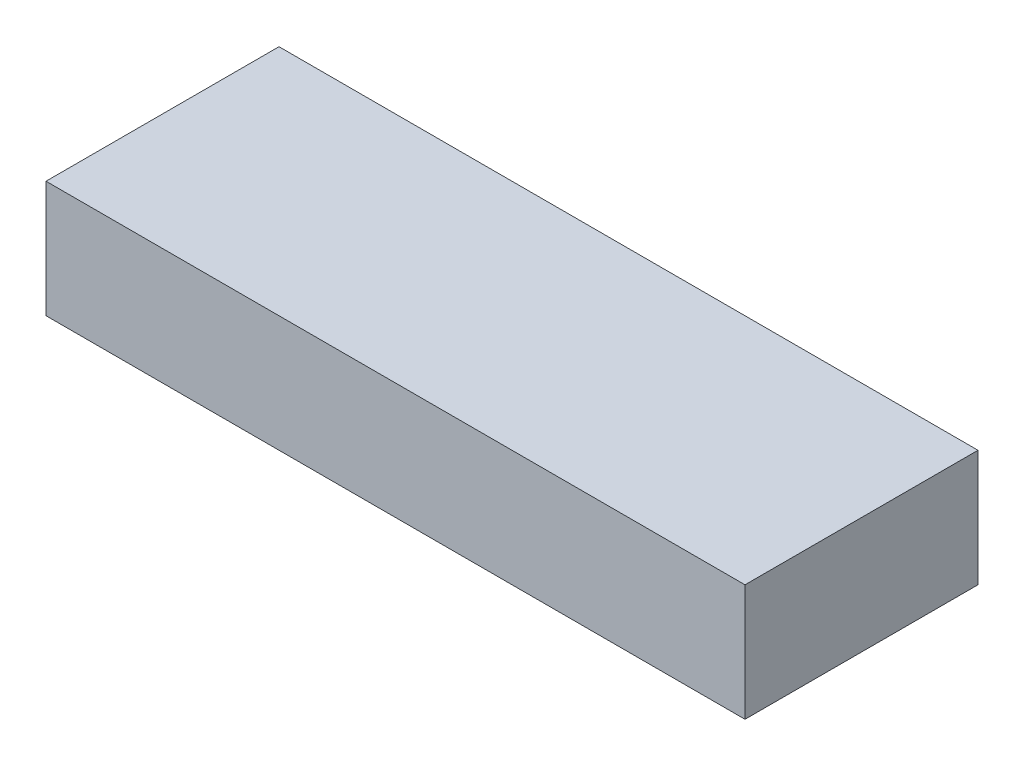
from build123d import *

# Parameters (mm, degrees)
SKETCH1_W             = 38.1
SKETCH1_H             = 12.7
BOSS_EXTRUDE1_DEPTH   = 6.35
BOSS_EXTRUDE2_DEPTH   = 0.508
BOSS_EXTRUDE2_2_DEPTH = 0.508
BOSS_EXTRUDE2_3_DEPTH = 0.508
BOSS_EXTRUDE2_4_DEPTH = 0.508
BOSS_EXTRUDE2_5_DEPTH = 0.508
BOSS_EXTRUDE2_6_DEPTH = 0.508


with BuildPart() as part:
    # Sketch1 → Boss-Extrude1 (new body)
    with BuildSketch(Plane(origin=(0, 0, 0), x_dir=(1, 0, 0), z_dir=(0, 1, 0))):
        Rectangle(SKETCH1_W, SKETCH1_H)
    extrude(amount=BOSS_EXTRUDE1_DEPTH)


with BuildPart() as body_2:
    # Sketch2 → Boss-Extrude2 (new body)
    with BuildSketch(Plane(origin=(0, 6.35, 0), x_dir=(1, 0, 0), z_dir=(0, 1, 0))):
        Polygon((-12.522431526, 2.146065762), (-11.733769667, 2.146065762), (-10.767870896, -0.80675208), (-9.795187936, 2.146065762), (-9.014158289, 2.146065762), (-8.298426451, -2.087267571), (-9.06758377, -2.087267571), (-9.519580298, 0.586550538), (-10.399828695, -2.087267571), (-11.141001238, -2.087267571), (-12.016161494, 0.586550538), (-12.467309998, -2.087267571), (-13.23731534, -2.087267571), align=None)
    extrude(amount=-BOSS_EXTRUDE2_DEPTH)


with BuildPart() as body_3:
    # Sketch2 → Boss-Extrude2 2 (new body)
    with BuildSketch(Plane(origin=(0, 6.35, 0), x_dir=(1, 0, 0), z_dir=(0, 1, 0))):
        with BuildLine():
            add(Edge.make_bspline(
                [(-5.603407755, 2.254612771), (-5.529806067, 2.252707091), (-5.384499664, 2.248944848), (-5.17080638, 2.217583617), (-4.96487339, 2.166484986), (-4.766793816, 2.095454193), (-4.577063625, 2.002567364), (-4.395013576, 1.8904579), (-4.221295764, 1.757009803), (-4.057690309, 1.605336197), (-3.906489362, 1.440397773), (-3.775473653, 1.262812236), (-3.663748263, 1.077181005), (-3.571149961, 0.883006677), (-3.500619118, 0.678944501), (-3.451124709, 0.466034924), (-3.419327003, 0.244338519), (-3.415669777, 0.093393484), (-3.413811067, 0.016678743)],
                knots=[0, 0, 0, 0, 0.000220721, 0.000435753, 0.000646365, 0.000856403, 0.00106576, 0.001278984, 0.001496765, 0.001721811, 0.001947536, 0.002167008, 0.002382688, 0.002596632, 0.002811184, 0.003029014, 0.003251603, 0.003481643, 0.003481643, 0.003481643, 0.003481643], degree=3))
            add(Edge.make_bspline(
                [(-3.413811067, 0.016678743), (-3.415790513, -0.0591716), (-3.419691075, -0.208637134), (-3.449826587, -0.42829052), (-3.500154489, -0.638919392), (-3.569489073, -0.841000511), (-3.660407992, -1.033555067), (-3.769954615, -1.217812494), (-3.90101967, -1.392062839), (-4.048822699, -1.556212592), (-4.211541007, -1.705213715), (-4.383885526, -1.836520698), (-4.565060476, -1.94778528), (-4.754800675, -2.038956497), (-4.95351301, -2.10971112), (-5.16070664, -2.159633649), (-5.376368742, -2.189972577), (-5.52302943, -2.193847661), (-5.59747159, -2.19581458)],
                knots=[0, 0, 0, 0, 0.000227498, 0.000448292, 0.000663647, 0.000876318, 0.001088005, 0.001301358, 0.001518283, 0.001741042, 0.001963118, 0.002179197, 0.002390088, 0.002599839, 0.002809591, 0.003021648, 0.003238241, 0.003461503, 0.003461503, 0.003461503, 0.003461503], degree=3))
            add(Edge.make_bspline(
                [(-5.59747159, -2.19581458), (-5.675329164, -2.194050157), (-5.828308655, -2.190583307), (-6.052194825, -2.157615148), (-6.266697121, -2.107953584), (-6.470013601, -2.033836364), (-6.664214868, -1.941183606), (-6.84787407, -1.82707618), (-7.020929484, -1.691702657), (-7.182388437, -1.538530004), (-7.32867064, -1.370925525), (-7.457793377, -1.193866256), (-7.56671127, -1.008704774), (-7.655428304, -0.81535442), (-7.72536925, -0.615016819), (-7.774704641, -0.406471856), (-7.803848233, -0.1902197), (-7.807907766, -0.043336912), (-7.809964913, 0.031095143)],
                knots=[0, 0, 0, 0, 0.000233428, 0.000458655, 0.000677506, 0.000892905, 0.001106449, 0.001322007, 0.001540154, 0.0017645, 0.001988669, 0.002206638, 0.002421018, 0.00263199, 0.002843861, 0.003056544, 0.003273863, 0.003497125, 0.003497125, 0.003497125, 0.003497125], degree=3))
            add(Edge.make_bspline(
                [(-7.809964913, 0.031095143), (-7.809319262, 0.081169133), (-7.808036135, 0.180683061), (-7.792579523, 0.328157623), (-7.770326445, 0.47275368), (-7.737415198, 0.613894725), (-7.697436445, 0.752576442), (-7.645638323, 0.887507948), (-7.586678043, 1.020130682), (-7.517788507, 1.148878203), (-7.441190004, 1.272565928), (-7.357614217, 1.390610398), (-7.266850996, 1.501584285), (-7.16919272, 1.606216862), (-7.064302845, 1.703820373), (-6.953561089, 1.79577653), (-6.834819707, 1.879642652), (-6.710677575, 1.957466916), (-6.581834577, 2.027842048), (-6.448815223, 2.087743256), (-6.314359972, 2.140053961), (-6.176672685, 2.181339882), (-6.037228925, 2.214966832), (-5.894539019, 2.237204912), (-5.749892088, 2.252661096), (-5.652351745, 2.253960669), (-5.603407755, 2.254612771)],
                knots=[0, 0, 0, 0, 0.00015016, 0.000298419, 0.00044439, 0.000588803, 0.000732899, 0.000877016, 0.001022016, 0.001168075, 0.001314688, 0.001458222, 0.001601661, 0.001744456, 0.001887252, 0.002031229, 0.002175945, 0.002323006, 0.002470616, 0.002615965, 0.002760383, 0.002903098, 0.003046877, 0.003190336, 0.003336063, 0.003482832, 0.003482832, 0.003482832, 0.003482832], degree=3))
        make_face()
        with BuildLine():
            add(Edge.make_bspline(
                [(-5.615280084, 1.494783711), (-5.66481401, 1.493454604), (-5.762574159, 1.49083148), (-5.905970494, 1.470846821), (-6.04363604, 1.438929048), (-6.174807662, 1.392696545), (-6.300053869, 1.333854302), (-6.419596684, 1.262607922), (-6.531780686, 1.176508389), (-6.638101741, 1.080178004), (-6.734145319, 0.972843817), (-6.819002849, 0.857816981), (-6.890014935, 0.73528959), (-6.949488001, 0.606399894), (-6.994258039, 0.469698562), (-7.026146395, 0.326256391), (-7.046298645, 0.175826223), (-7.048838861, 0.073278173), (-7.050135853, 0.02091886)],
                knots=[0, 0, 0, 0, 0.000148559, 0.000293196, 0.000433479, 0.000571871, 0.00070958, 0.000848034, 0.000988469, 0.001133133, 0.001277857, 0.001419824, 0.001561198, 0.001701985, 0.001844919, 0.001991813, 0.002142335, 0.002299366, 0.002299366, 0.002299366, 0.002299366], degree=3))
            add(Edge.make_bspline(
                [(-7.050135853, 0.02091886), (-7.04841624, -0.037107036), (-7.045046083, -0.150828179), (-7.021333251, -0.316721518), (-6.980762956, -0.473391311), (-6.922180239, -0.620071311), (-6.8495223, -0.758390289), (-6.759292671, -0.886652949), (-6.652952646, -1.005627268), (-6.571029151, -1.075089431), (-6.529449421, -1.110344494)],
                knots=[0, 0, 0, 0, 0.000174052, 0.000341112, 0.00050155, 0.000658395, 0.000813933, 0.000969205, 0.001127733, 0.001291118, 0.001291118, 0.001291118, 0.001291118], degree=3))
            add(Edge.make_bspline(
                [(-6.529449421, -1.110344494), (-6.495387685, -1.136389581), (-6.428031628, -1.187892954), (-6.320516696, -1.253905093), (-6.209797487, -1.310484081), (-6.095038486, -1.356199233), (-5.976482057, -1.392158004), (-5.854144458, -1.41733934), (-5.728199032, -1.433142806), (-5.643028832, -1.43503162), (-5.600015661, -1.43598552)],
                knots=[0, 0, 0, 0, 0.000128564, 0.000254232, 0.000377869, 0.000501171, 0.00062431, 0.000749047, 0.00087548, 0.00100448, 0.00100448, 0.00100448, 0.00100448], degree=3))
            add(Edge.make_bspline(
                [(-5.600015661, -1.43598552), (-5.551333471, -1.434645144), (-5.455549733, -1.432007912), (-5.314822798, -1.412269275), (-5.18000212, -1.378864375), (-5.050250721, -1.333037439), (-4.925942746, -1.273456381), (-4.807685722, -1.200000161), (-4.695272312, -1.113570728), (-4.589086709, -1.015975314), (-4.492028048, -0.908218304), (-4.407347598, -0.792577927), (-4.334077683, -0.671602087), (-4.27584136, -0.543578553), (-4.229302559, -0.409715809), (-4.197797996, -0.269421004), (-4.177475505, -0.123272487), (-4.174934573, -0.023813257), (-4.173640127, 0.026855025)],
                knots=[0, 0, 0, 0, 0.000146018, 0.000287294, 0.000425304, 0.000562096, 0.000699402, 0.000838015, 0.000978963, 0.0011242, 0.001270122, 0.001413275, 0.001553619, 0.001693636, 0.001834431, 0.001978017, 0.002124335, 0.002276283, 0.002276283, 0.002276283, 0.002276283], degree=3))
            add(Edge.make_bspline(
                [(-4.173640127, 0.026855025), (-4.174979361, 0.07723195), (-4.17761544, 0.176391245), (-4.197388818, 0.322164015), (-4.230581874, 0.461839459), (-4.276546423, 0.595645683), (-4.335240718, 0.723713866), (-4.407822168, 0.845593644), (-4.494036094, 0.961167191), (-4.591898288, 1.069646915), (-4.698415271, 1.169332833), (-4.812771895, 1.255842089), (-4.931768334, 1.331015882), (-5.058134947, 1.389903996), (-5.189286378, 1.436820031), (-5.32602292, 1.471369673), (-5.468862472, 1.490691087), (-5.566039172, 1.493407343), (-5.615280084, 1.494783711)],
                knots=[0, 0, 0, 0, 0.000151101, 0.000297418, 0.000440373, 0.000581168, 0.000721184, 0.000862257, 0.001005914, 0.001153033, 0.001300045, 0.001442855, 0.001582635, 0.001721473, 0.001860148, 0.002000007, 0.002143804, 0.002291516, 0.002291516, 0.002291516, 0.002291516], degree=3))
        make_face(mode=Mode.SUBTRACT)
    extrude(amount=-BOSS_EXTRUDE2_2_DEPTH)


with BuildPart() as body_4:
    # Sketch2 → Boss-Extrude2 3 (new body)
    with BuildSketch(Plane(origin=(0, 6.35, 0), x_dir=(1, 0, 0), z_dir=(0, 1, 0))):
        Polygon((-3.088170041, 2.146065762), (-0.808682862, 2.146065762), (-0.808682862, 1.386236702), (-1.568511921, 1.386236702), (-1.568511921, -2.087267571), (-2.328340981, -2.087267571), (-2.328340981, 1.386236702), (-3.088170041, 1.386236702), align=None)
    extrude(amount=-BOSS_EXTRUDE2_3_DEPTH)


with BuildPart() as body_5:
    # Sketch2 → Boss-Extrude2 4 (new body)
    with BuildSketch(Plane(origin=(0, 6.35, 0), x_dir=(1, 0, 0), z_dir=(0, 1, 0))):
        with BuildLine():
            add(Edge.make_bspline(
                [(1.777788826, 2.254612771), (1.851390515, 2.252707091), (1.996696918, 2.248944848), (2.210390201, 2.217583617), (2.416323191, 2.166484986), (2.614402766, 2.095454193), (2.804132956, 2.002567364), (2.986183005, 1.8904579), (3.159900817, 1.757009803), (3.323506272, 1.605336197), (3.474707219, 1.440397773), (3.605722928, 1.262812236), (3.717448318, 1.077181005), (3.810046621, 0.883006677), (3.880577463, 0.678944501), (3.930071873, 0.466034924), (3.961869579, 0.244338519), (3.965526804, 0.093393484), (3.967385514, 0.016678743)],
                knots=[0, 0, 0, 0, 0.000220721, 0.000435753, 0.000646365, 0.000856403, 0.00106576, 0.001278984, 0.001496765, 0.001721811, 0.001947536, 0.002167008, 0.002382688, 0.002596632, 0.002811184, 0.003029014, 0.003251603, 0.003481643, 0.003481643, 0.003481643, 0.003481643], degree=3))
            add(Edge.make_bspline(
                [(3.967385514, 0.016678743), (3.965406068, -0.0591716), (3.961505506, -0.208637134), (3.931369994, -0.42829052), (3.881042093, -0.638919392), (3.811707508, -0.841000511), (3.720788589, -1.033555067), (3.611241966, -1.217812494), (3.480176911, -1.392062839), (3.332373882, -1.556212592), (3.169655575, -1.705213715), (2.997311055, -1.836520698), (2.816136105, -1.94778528), (2.626395907, -2.038956497), (2.427683571, -2.10971112), (2.220489941, -2.159633649), (2.004827839, -2.189972577), (1.858167152, -2.193847661), (1.783724991, -2.19581458)],
                knots=[0, 0, 0, 0, 0.000227498, 0.000448292, 0.000663647, 0.000876318, 0.001088005, 0.001301358, 0.001518283, 0.001741042, 0.001963118, 0.002179197, 0.002390088, 0.002599839, 0.002809591, 0.003021648, 0.003238241, 0.003461503, 0.003461503, 0.003461503, 0.003461503], degree=3))
            add(Edge.make_bspline(
                [(1.783724991, -2.19581458), (1.705867417, -2.194050157), (1.552887926, -2.190583307), (1.329001756, -2.157615148), (1.11449946, -2.107953584), (0.911182981, -2.033836364), (0.716981713, -1.941183606), (0.533322511, -1.82707618), (0.360267097, -1.691702657), (0.198808144, -1.538530004), (0.052525941, -1.370925525), (-0.076596796, -1.193866256), (-0.185514689, -1.008704774), (-0.274231723, -0.81535442), (-0.344172669, -0.615016819), (-0.39350806, -0.406471856), (-0.422651652, -0.1902197), (-0.426711185, -0.043336912), (-0.428768332, 0.031095143)],
                knots=[0, 0, 0, 0, 0.000233428, 0.000458655, 0.000677506, 0.000892905, 0.001106449, 0.001322007, 0.001540154, 0.0017645, 0.001988669, 0.002206638, 0.002421018, 0.00263199, 0.002843861, 0.003056544, 0.003273863, 0.003497125, 0.003497125, 0.003497125, 0.003497125], degree=3))
            add(Edge.make_bspline(
                [(-0.428768332, 0.031095143), (-0.428122681, 0.081169133), (-0.426839554, 0.180683061), (-0.411382941, 0.328157623), (-0.389129863, 0.47275368), (-0.356218617, 0.613894725), (-0.316239864, 0.752576442), (-0.264441742, 0.887507948), (-0.205481462, 1.020130682), (-0.136591926, 1.148878203), (-0.059993422, 1.272565928), (0.023582364, 1.390610398), (0.114345585, 1.501584285), (0.212003861, 1.606216862), (0.316893736, 1.703820373), (0.427635492, 1.79577653), (0.546376874, 1.879642652), (0.670519006, 1.957466916), (0.799362004, 2.027842048), (0.932381359, 2.087743256), (1.066836609, 2.140053961), (1.204523896, 2.181339882), (1.343967656, 2.214966832), (1.486657562, 2.237204912), (1.631304493, 2.252661096), (1.728844836, 2.253960669), (1.777788826, 2.254612771)],
                knots=[0, 0, 0, 0, 0.00015016, 0.000298419, 0.00044439, 0.000588803, 0.000732899, 0.000877016, 0.001022016, 0.001168075, 0.001314688, 0.001458222, 0.001601661, 0.001744456, 0.001887252, 0.002031229, 0.002175945, 0.002323006, 0.002470616, 0.002615965, 0.002760383, 0.002903098, 0.003046877, 0.003190336, 0.003336063, 0.003482832, 0.003482832, 0.003482832, 0.003482832], degree=3))
        make_face()
        with BuildLine():
            add(Edge.make_bspline(
                [(1.765916497, 1.494783711), (1.716382571, 1.493454604), (1.618622422, 1.49083148), (1.475226087, 1.470846821), (1.337560541, 1.438929048), (1.206388919, 1.392696545), (1.081142712, 1.333854302), (0.961599897, 1.262607922), (0.849415895, 1.176508389), (0.74309484, 1.080178004), (0.647051262, 0.972843817), (0.562193732, 0.857816981), (0.491181646, 0.73528959), (0.43170858, 0.606399894), (0.386938542, 0.469698562), (0.355050187, 0.326256391), (0.334897936, 0.175826223), (0.33235772, 0.073278173), (0.331060728, 0.02091886)],
                knots=[0, 0, 0, 0, 0.000148559, 0.000293196, 0.000433479, 0.000571871, 0.00070958, 0.000848034, 0.000988469, 0.001133133, 0.001277857, 0.001419824, 0.001561198, 0.001701985, 0.001844919, 0.001991813, 0.002142335, 0.002299366, 0.002299366, 0.002299366, 0.002299366], degree=3))
            add(Edge.make_bspline(
                [(0.331060728, 0.02091886), (0.332780341, -0.037107036), (0.336150498, -0.150828179), (0.35986333, -0.316721518), (0.400433625, -0.473391311), (0.459016342, -0.620071311), (0.531674281, -0.758390289), (0.62190391, -0.886652949), (0.728243936, -1.005627268), (0.81016743, -1.075089431), (0.85174716, -1.110344494)],
                knots=[0, 0, 0, 0, 0.000174052, 0.000341112, 0.00050155, 0.000658395, 0.000813933, 0.000969205, 0.001127733, 0.001291118, 0.001291118, 0.001291118, 0.001291118], degree=3))
            add(Edge.make_bspline(
                [(0.85174716, -1.110344494), (0.885808897, -1.136389581), (0.953164954, -1.187892954), (1.060679885, -1.253905093), (1.171399094, -1.310484081), (1.286158096, -1.356199233), (1.404714524, -1.392158004), (1.527052123, -1.41733934), (1.652997549, -1.433142806), (1.738167749, -1.43503162), (1.78118092, -1.43598552)],
                knots=[0, 0, 0, 0, 0.000128564, 0.000254232, 0.000377869, 0.000501171, 0.00062431, 0.000749047, 0.00087548, 0.00100448, 0.00100448, 0.00100448, 0.00100448], degree=3))
            add(Edge.make_bspline(
                [(1.78118092, -1.43598552), (1.82986311, -1.434645144), (1.925646848, -1.432007912), (2.066373783, -1.412269275), (2.201194461, -1.378864375), (2.33094586, -1.333037439), (2.455253835, -1.273456381), (2.573510859, -1.200000161), (2.685924269, -1.113570728), (2.792109872, -1.015975314), (2.889168533, -0.908218304), (2.973848983, -0.792577927), (3.047118898, -0.671602087), (3.105355221, -0.543578553), (3.151894022, -0.409715809), (3.183398585, -0.269421004), (3.203721076, -0.123272487), (3.206262008, -0.023813257), (3.207556455, 0.026855025)],
                knots=[0, 0, 0, 0, 0.000146018, 0.000287294, 0.000425304, 0.000562096, 0.000699402, 0.000838015, 0.000978963, 0.0011242, 0.001270122, 0.001413275, 0.001553619, 0.001693636, 0.001834431, 0.001978017, 0.002124335, 0.002276283, 0.002276283, 0.002276283, 0.002276283], degree=3))
            add(Edge.make_bspline(
                [(3.207556455, 0.026855025), (3.20621722, 0.07723195), (3.203581141, 0.176391245), (3.183807763, 0.322164015), (3.150614707, 0.461839459), (3.104650158, 0.595645683), (3.045955863, 0.723713866), (2.973374413, 0.845593644), (2.887160487, 0.961167191), (2.789298293, 1.069646915), (2.68278131, 1.169332833), (2.568424686, 1.255842089), (2.449428247, 1.331015882), (2.323061634, 1.389903996), (2.191910204, 1.436820031), (2.055173661, 1.471369673), (1.912334109, 1.490691087), (1.815157409, 1.493407343), (1.765916497, 1.494783711)],
                knots=[0, 0, 0, 0, 0.000151101, 0.000297418, 0.000440373, 0.000581168, 0.000721184, 0.000862257, 0.001005914, 0.001153033, 0.001300045, 0.001442855, 0.001582635, 0.001721473, 0.001860148, 0.002000007, 0.002143804, 0.002291516, 0.002291516, 0.002291516, 0.002291516], degree=3))
        make_face(mode=Mode.SUBTRACT)
    extrude(amount=-BOSS_EXTRUDE2_4_DEPTH)


with BuildPart() as body_6:
    # Sketch2 → Boss-Extrude2 5 (new body)
    with BuildSketch(Plane(origin=(0, 6.35, 0), x_dir=(1, 0, 0), z_dir=(0, 1, 0))):
        with BuildLine():
            Line((4.727214574, 2.146065762), (5.612551113, 2.146065762))
            add(Edge.make_bspline(
                [(5.612551113, 2.146065762), (5.671071588, 2.145858048), (5.783622948, 2.145458555), (5.94591586, 2.139155618), (6.095004219, 2.130384564), (6.231108763, 2.116999702), (6.354171265, 2.099252994), (6.464315062, 2.078332561), (6.561536934, 2.054489243), (6.646656815, 2.024778587), (6.723473298, 1.991265418), (6.795076939, 1.952758172), (6.863047422, 1.909685639), (6.926930438, 1.860914466), (6.987281144, 1.807322032), (7.044213395, 1.748854393), (7.096922688, 1.685015766), (7.145082642, 1.61620953), (7.188976564, 1.543826948), (7.227769585, 1.467768639), (7.259316134, 1.387981707), (7.287190892, 1.305619247), (7.307268177, 1.219503872), (7.321231635, 1.130473929), (7.331455133, 1.038216024), (7.332042935, 0.975540099), (7.332342779, 0.943568433)],
                knots=[0, 0, 0, 0, 0.000175549, 0.00033763, 0.000487174, 0.000623534, 0.00074778, 0.000860044, 0.000959797, 0.001047763, 0.001130165, 0.001210977, 0.001291432, 0.001371318, 0.001451813, 0.001533373, 0.001615893, 0.001699886, 0.001785112, 0.001869685, 0.001955666, 0.002042285, 0.00213032, 0.002220522, 0.002312582, 0.002408443, 0.002408443, 0.002408443, 0.002408443], degree=3))
            add(Edge.make_bspline(
                [(7.332342779, 0.943568433), (7.331563892, 0.910197358), (7.330036635, 0.844762763), (7.32181, 0.74864468), (7.306774296, 0.65668562), (7.284000534, 0.56915483), (7.257825053, 0.484962887), (7.223018378, 0.405663184), (7.183735605, 0.330102422), (7.137080603, 0.259349437), (7.085879017, 0.191832663), (7.02633265, 0.130138919), (6.962299192, 0.0709524), (6.890179088, 0.017980348), (6.81315146, -0.032359015), (6.72968585, -0.077979884), (6.640326983, -0.120029063), (6.577503275, -0.143478589), (6.545376967, -0.155470028)],
                knots=[0, 0, 0, 0, 0.000100124, 0.000196325, 0.000289175, 0.000379262, 0.000467493, 0.000553344, 0.000638696, 0.000722668, 0.000807309, 0.000892492, 0.000979541, 0.001068584, 0.001160554, 0.001255442, 0.001353703, 0.001456538, 0.001456538, 0.001456538, 0.001456538], degree=3))
            Line((6.545376967, -0.155470028), (7.522300044, -2.087267571))
            Line((7.522300044, -2.087267571), (6.677668634, -2.087267571))
            Line((6.677668634, -2.087267571), (5.744842779, -0.241968426))
            Line((5.744842779, -0.241968426), (5.487043634, -0.241968426))
            Line((5.487043634, -0.241968426), (5.487043634, -2.087267571))
            Line((5.487043634, -2.087267571), (4.727214574, -2.087267571))
            Line((4.727214574, -2.087267571), (4.727214574, 2.146065762))
        make_face()
        with BuildLine():
            Line((5.487043634, 0.517860634), (5.783003837, 0.517860634))
            add(Edge.make_bspline(
                [(5.783003837, 0.517860634), (5.819187432, 0.518268158), (5.888471242, 0.519048479), (5.98811046, 0.52266793), (6.078606632, 0.53138902), (6.16034838, 0.54240779), (6.233747021, 0.555130552), (6.298147865, 0.573363043), (6.354543231, 0.592899618), (6.40226483, 0.617178513), (6.443037069, 0.644788882), (6.478241287, 0.676154948), (6.507360223, 0.712457175), (6.531326593, 0.752709026), (6.549969823, 0.797266518), (6.563577952, 0.845640511), (6.571182884, 0.898382047), (6.572057858, 0.934780888), (6.57251372, 0.953744715)],
                knots=[0, 0, 0, 0, 0.00010856, 0.00020787, 0.000299003, 0.000381157, 0.000455338, 0.000522203, 0.000581758, 0.000634096, 0.000682314, 0.000729148, 0.000774972, 0.000821366, 0.000869248, 0.000919453, 0.000971743, 0.001028617, 0.001028617, 0.001028617, 0.001028617], degree=3))
            add(Edge.make_bspline(
                [(6.57251372, 0.953744715), (6.571651871, 0.976180307), (6.569958929, 1.020250869), (6.553159687, 1.083697025), (6.526418921, 1.142420784), (6.489764656, 1.196156816), (6.443603375, 1.243265532), (6.390629663, 1.284792239), (6.329700219, 1.317628453), (6.273284139, 1.339286869), (6.221958692, 1.352245324), (6.175639097, 1.361901849), (6.122000726, 1.368745706), (6.061003086, 1.376004834), (5.992801662, 1.380712011), (5.917024715, 1.384147312), (5.833889877, 1.385552863), (5.775936999, 1.386002193), (5.745690803, 1.386236702)],
                knots=[0, 0, 0, 0, 6.7187e-05, 0.000131976, 0.000195351, 0.000260035, 0.000326007, 0.000392499, 0.000461195, 0.000532856, 0.000573171, 0.000619905, 0.000674712, 0.000735303, 0.000804181, 0.000879731, 0.000962855, 0.001053597, 0.001053597, 0.001053597, 0.001053597], degree=3))
            Line((5.745690803, 1.386236702), (5.487043634, 1.386236702))
            Line((5.487043634, 1.386236702), (5.487043634, 0.517860634))
        make_face(mode=Mode.SUBTRACT)
    extrude(amount=-BOSS_EXTRUDE2_5_DEPTH)


with BuildPart() as body_7:
    # Sketch2 → Boss-Extrude2 6 (new body)
    with BuildSketch(Plane(origin=(0, 6.35, 0), x_dir=(1, 0, 0), z_dir=(0, 1, 0))):
        with BuildLine():
            Line((10.26311201, 0.734954651), (9.50328295, 0.734954651))
            add(Edge.make_bspline(
                [(9.50328295, 0.734954651), (9.506564536, 0.7924317), (9.512976556, 0.904738402), (9.538481953, 1.067867482), (9.572658309, 1.222006525), (9.618271193, 1.366616335), (9.675586766, 1.501644365), (9.743130152, 1.627550934), (9.822626929, 1.74367314), (9.912385145, 1.849450977), (10.010880953, 1.94434525), (10.116069483, 2.028484475), (10.229559735, 2.097914045), (10.34927815, 2.155048154), (10.475204341, 2.200695652), (10.608529768, 2.231214698), (10.748100028, 2.251882495), (10.843647173, 2.25369101), (10.89234545, 2.254612771)],
                knots=[0, 0, 0, 0, 0.000172618, 0.000337285, 0.000494666, 0.000645929, 0.000791465, 0.000934135, 0.001073853, 0.001212839, 0.001349578, 0.001483609, 0.00161611, 0.001747728, 0.001881041, 0.002017002, 0.002157439, 0.00230342, 0.00230342, 0.00230342, 0.00230342], degree=3))
            add(Edge.make_bspline(
                [(10.89234545, 2.254612771), (10.952121894, 2.252747588), (11.068819522, 2.249106314), (11.238390431, 2.218045042), (11.396751119, 2.166090264), (11.543786474, 2.093495738), (11.678244758, 2.001272001), (11.800103673, 1.891310289), (11.905678012, 1.761303547), (11.995637147, 1.616661143), (12.070382437, 1.463505194), (12.122760822, 1.305135591), (12.157188571, 1.145754822), (12.160860504, 1.03843588), (12.16268466, 0.985121585)],
                knots=[0, 0, 0, 0, 0.000179222, 0.000349884, 0.000515076, 0.000677775, 0.000840074, 0.001002764, 0.001168459, 0.001340689, 0.001512888, 0.001678348, 0.001840169, 0.001999922, 0.001999922, 0.001999922, 0.001999922], degree=3))
            add(Edge.make_bspline(
                [(12.16268466, 0.985121585), (12.16197443, 0.952873331), (12.160544912, 0.887965562), (12.150605286, 0.789744178), (12.135693884, 0.689694214), (12.113211123, 0.587901454), (12.085173276, 0.484337365), (12.051159316, 0.378692014), (12.010380255, 0.271564372), (11.963516612, 0.161748736), (11.907608167, 0.048888577), (11.842510555, -0.068707922), (11.766495937, -0.190936444), (11.680482473, -0.318487132), (11.584052417, -0.451158817), (11.47673503, -0.588551852), (11.359766355, -0.731150365), (11.276750396, -0.826469469), (11.234098923, -0.875441984)],
                knots=[0, 0, 0, 0, 9.6734e-05, 0.000194702, 0.000295926, 0.00040005, 0.000507227, 0.000617718, 0.000732852, 0.000850996, 0.000975771, 0.001110524, 0.00125408, 0.001407432, 0.001571968, 0.001746009, 0.00193038, 0.002125197, 0.002125197, 0.002125197, 0.002125197], degree=3))
            Line((11.234098923, -0.875441984), (10.792278677, -1.381712016))
            Line((10.792278677, -1.381712016), (12.216958164, -1.381712016))
            Line((12.216958164, -1.381712016), (12.216958164, -2.087267571))
            Line((12.216958164, -2.087267571), (9.394735942, -2.087267571))
            Line((9.394735942, -2.087267571), (9.394735942, -1.7022649))
            Line((9.394735942, -1.7022649), (10.648114681, -0.368323928))
            add(Edge.make_bspline(
                [(10.648114681, -0.368323928), (10.684403217, -0.329412456), (10.754683348, -0.254052473), (10.854684733, -0.143378321), (10.945177152, -0.038351193), (11.024284172, 0.062147239), (11.096157228, 0.154857214), (11.157591505, 0.242573127), (11.20914908, 0.324501995), (11.265122139, 0.4232939), (11.318278146, 0.541120827), (11.367052, 0.676862278), (11.396783039, 0.806599843), (11.400886863, 0.891139629), (11.4028556, 0.931696104)],
                knots=[0, 0, 0, 0, 0.000159618, 0.000309132, 0.000447472, 0.000575408, 0.000692779, 0.00079935, 0.000896522, 0.000983091, 0.001139811, 0.001283565, 0.001415467, 0.001537093, 0.001537093, 0.001537093, 0.001537093], degree=3))
            add(Edge.make_bspline(
                [(11.4028556, 0.931696104), (11.401383623, 0.970931365), (11.398531431, 1.046955973), (11.367188153, 1.155100574), (11.318630061, 1.25301447), (11.250204851, 1.337771884), (11.167320491, 1.407422672), (11.071539827, 1.45922697), (10.963643754, 1.489117813), (10.888006551, 1.492859079), (10.849096252, 1.494783711)],
                knots=[0, 0, 0, 0, 0.000117398, 0.000227478, 0.000334806, 0.000443406, 0.000551767, 0.000657621, 0.000767701, 0.000884325, 0.000884325, 0.000884325, 0.000884325], degree=3))
            add(Edge.make_bspline(
                [(10.849096252, 1.494783711), (10.828994695, 1.494072729), (10.789421554, 1.492673047), (10.731252128, 1.48335574), (10.675899741, 1.466934959), (10.622748289, 1.444933425), (10.572365018, 1.415770233), (10.524877011, 1.379821953), (10.479783922, 1.338002111), (10.437292565, 1.290441474), (10.398619884, 1.237363789), (10.36427095, 1.179253812), (10.3358701, 1.116147614), (10.310864959, 1.048878293), (10.291579798, 0.976723322), (10.277537808, 0.90011454), (10.266862621, 0.819176579), (10.264384957, 0.763539342), (10.26311201, 0.734954651)],
                knots=[0, 0, 0, 0, 6.0305e-05, 0.00011872, 0.000176149, 0.000233162, 0.000290909, 0.00035027, 0.000411481, 0.000475145, 0.000541296, 0.000608199, 0.000677259, 0.000748624, 0.000823298, 0.00090097, 0.000982173, 0.001067974, 0.001067974, 0.001067974, 0.001067974], degree=3))
        make_face()
    extrude(amount=-BOSS_EXTRUDE2_6_DEPTH)


solid = Compound([part.part, body_2.part, body_3.part, body_4.part, body_5.part, body_6.part, body_7.part])
